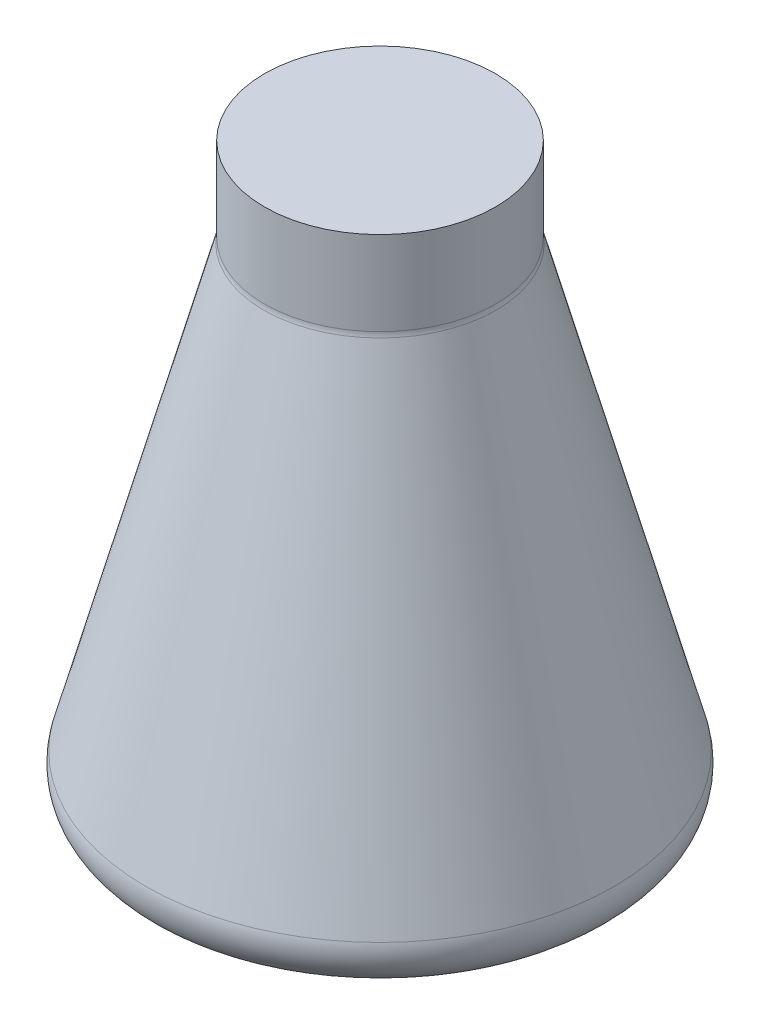
from build123d import *

# Parameters (mm, degrees)
FILLET3_R = 20


with BuildPart() as part:
    # Sketch2 → Revolve3 (revolve)
    with BuildSketch(Plane.XY):
        with BuildLine():
            Line((-0.225402923, 53.386649963), (-60.225402923, 53.386649963))
            Line((-60.225402923, 53.386649963), (-60.225402923, 9.704723781))
            ThreePointArc((-60.225402923, 9.704723781), (-60.311153141, 8.397952475), (-60.566933173, 7.113592353))
            Line((-60.566933173, 7.113592353), (-128.635671951, -246.613350037))
            Line((-128.635671951, -246.613350037), (-0.225402923, -246.613350037))
            Line((-0.225402923, -246.613350037), (-0.225402923, 53.386649963))
        make_face()
    revolve(axis=Axis((-0.225402923, 53.386649963, 0), (0, -1, 0)))

    # Fillet3
    fillet3_edges = [part.edges().sort_by_distance(p)[0] for p in [
        (128.184866104, -246.613350037, 0),
    ]]
    fillet(fillet3_edges, radius=FILLET3_R)


solid = part.part
